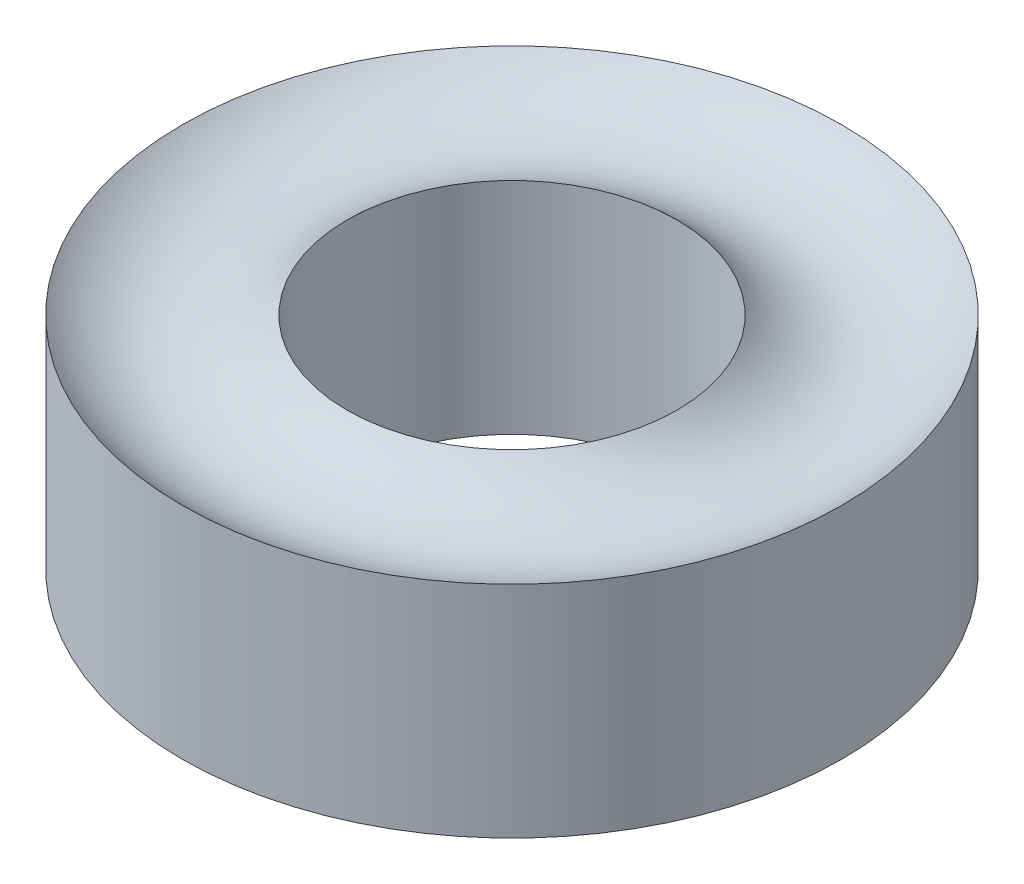
from build123d import *


with BuildPart() as part:
    # Sketch2 → Revolve1 (revolve)
    with BuildSketch(Plane.XY):
        with BuildLine():
            Line((1.5, 0), (1.5, 2))
            ThreePointArc((1.5, 2), (2.25, 1.689339828), (3, 2))
            Line((3, 2), (3, 0))
            ThreePointArc((3, 0), (2.25, 0.310660172), (1.5, 0))
        make_face()
    revolve(axis=Axis((0, 0, 0), (0, 1, 0)))


solid = part.part
